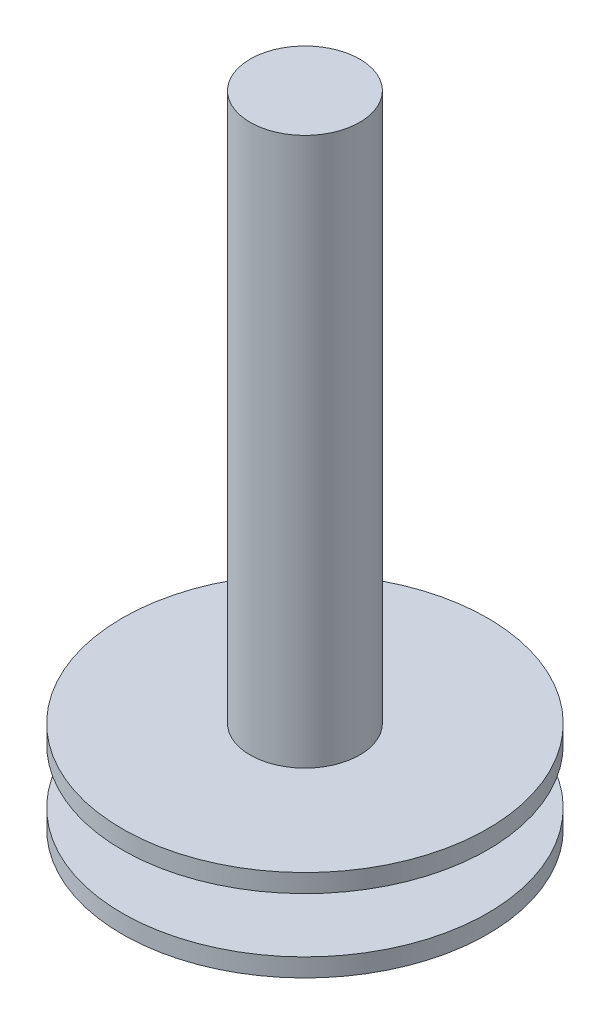
from build123d import *

# Parameters (mm, degrees)
SKETCH2_R           = 3
BOSS_EXTRUDE1_DEPTH = 30


with BuildPart() as part:
    # Sketch1 → Revolve1 (revolve)
    with BuildSketch(Plane.XY):
        Polygon((0, 0), (10, 0), (10, 1), (5, 1), (5, 4), (10, 4), (10, 5), (0, 5), align=None)
    revolve(axis=Axis((0, 5, 0), (0, -1, 0)))

    # Sketch2 → Boss-Extrude1 (add)
    with BuildSketch(Plane(origin=(0, 5, 0), x_dir=(1, 0, 0), z_dir=(0, 1, 0))):
        Circle(SKETCH2_R)
    extrude(amount=BOSS_EXTRUDE1_DEPTH)


solid = part.part
